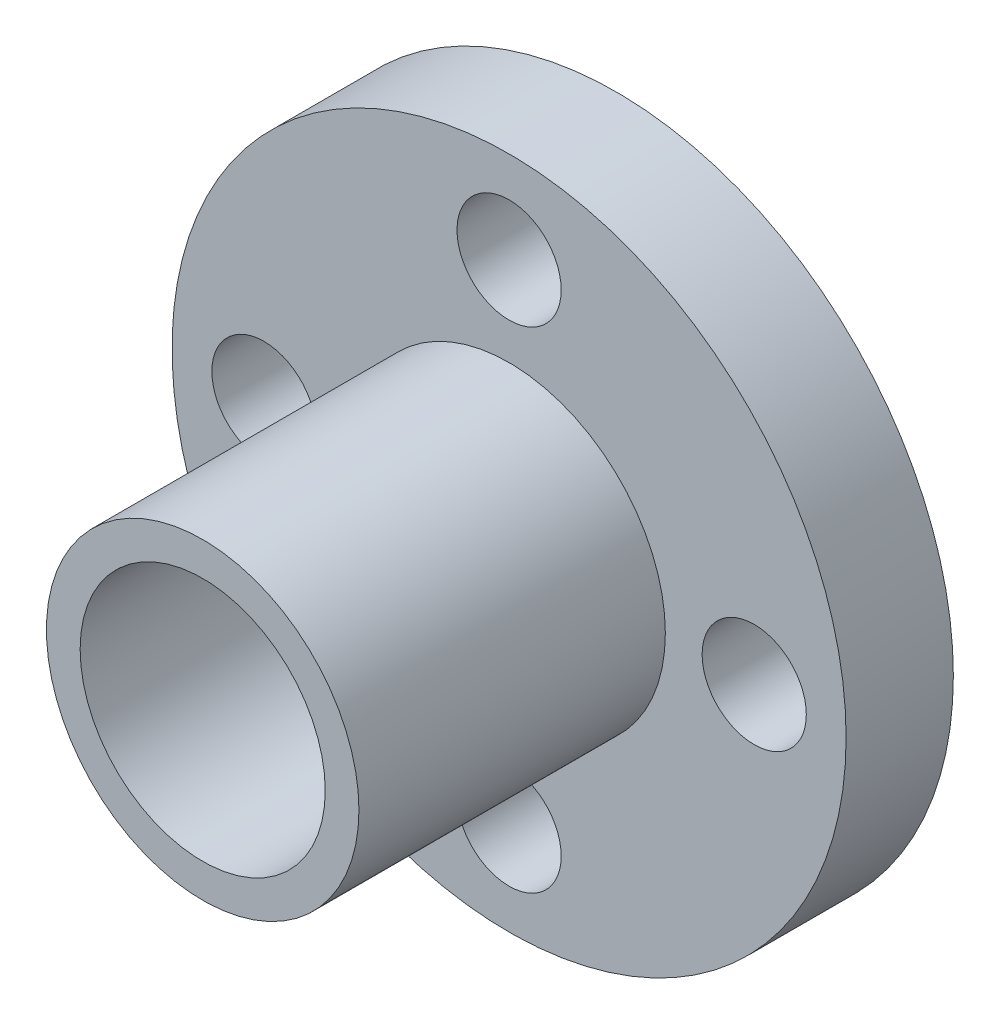
from build123d import *

# Parameters (mm, degrees)
SKETCH_1_R          = 11
EXTRUDE_1_DEPTH     = 3.5
SKETCH_2_R          = 5.1
EXTRUDE_2_DEPTH     = 10
EXTRUDE_START       = -3.5
SKETCH_2_3_R        = 5.1
EXTRUDE_3_DEPTH     = 1.5
SKETCH_3_R          = 4
CUT_EXTRUDE_1_DEPTH = 16
HOLE_WIZARD_M3_1_D  = 3.4


with BuildPart() as part:
    # Sketch 1 → Extrude 1 (new body)
    with BuildSketch(Plane.XY):
        Circle(SKETCH_1_R)
    extrude(amount=EXTRUDE_1_DEPTH)

    # Sketch 2 → Extrude 2 (add)
    with BuildSketch(Plane.XY.offset(3.5)):
        Circle(SKETCH_2_R)
    extrude(amount=EXTRUDE_2_DEPTH)

    # Sketch 2_3 → Extrude 3 (add)
    with BuildSketch(Plane.XY.offset(3.5).offset(EXTRUDE_START)):
        Circle(SKETCH_2_3_R)
    extrude(amount=-EXTRUDE_3_DEPTH)

    # Sketch 3 → Cut-Extrude 1 (cut, through all)
    with BuildSketch(Plane(origin=(0, 0, -1.5), x_dir=(-1, 0, 0), z_dir=(0, 0, -1))):
        Circle(SKETCH_3_R)
    extrude(amount=-CUT_EXTRUDE_1_DEPTH, mode=Mode.SUBTRACT)

    # Hole Wizard M3 _1 (through all)
    with Locations(Plane(origin=(0, 0, 0), x_dir=(-1, 0, 0), z_dir=(0, 0, -1))):
        with Locations((-8, 0), (0, 8), (8, 0), (0, -8)):
            Hole(HOLE_WIZARD_M3_1_D / 2)


solid = part.part
